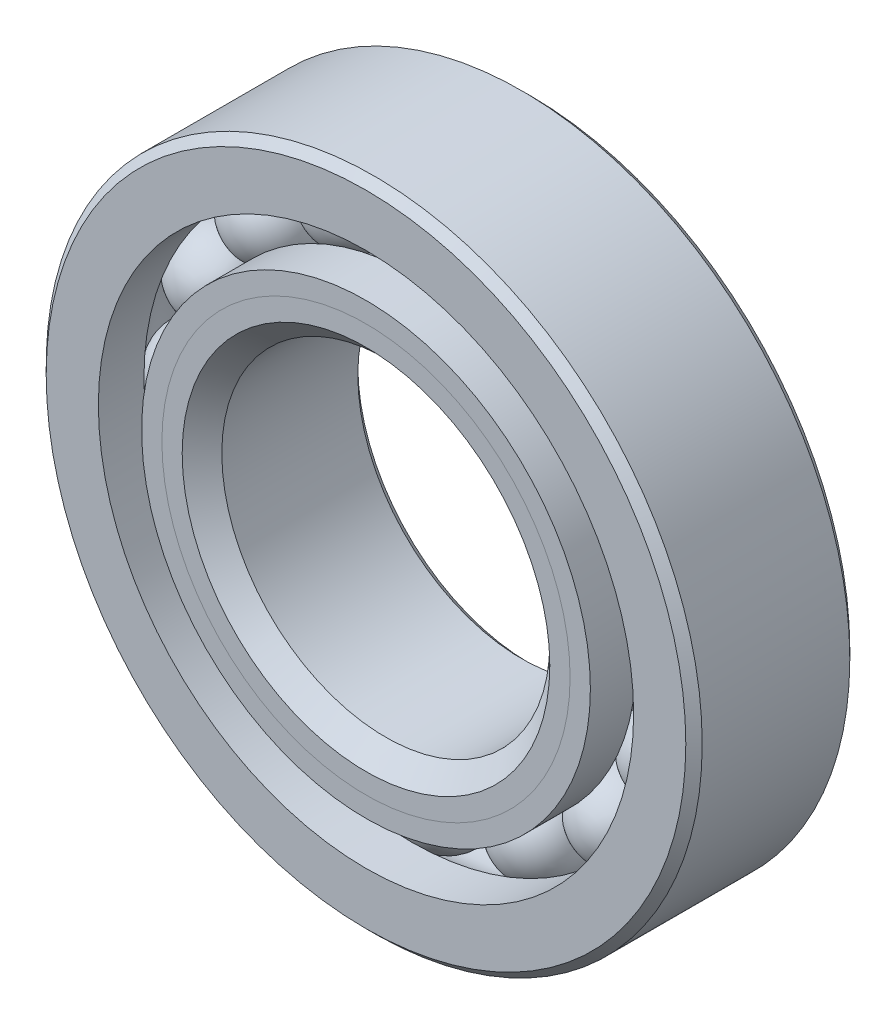
from build123d import *

# Parameters (mm, degrees)
CIRPATTERN1_COUNT = 16


with BuildPart() as part:
    # Sketch1 → Revolve1 (revolve)
    with BuildSketch(Plane(origin=(0, 0, 0), x_dir=(0, 0, -1), z_dir=(1, 0, 0))):
        with BuildLine():
            Line((5.715, 25.4), (-5.715, 25.4))
            Line((-5.715, 25.4), (-6.35, 24.765))
            Line((-6.35, 24.765), (-6.35, 20.724725275))
            Line((-6.35, 20.724725275), (-2.822222222, 20.724725275))
            ThreePointArc((-2.822222222, 20.724725275), (0, 22.331713427), (2.822222222, 20.724725275))
            Line((2.822222222, 20.724725275), (6.35, 20.724725275))
            Line((6.35, 20.724725275), (6.35, 24.765))
            Line((6.35, 24.765), (5.715, 25.4))
        make_face()
    revolve(axis=Axis((0, 0, 6.35), (0, 0, -1)))


with BuildPart() as body_2:
    # Sketch2 → Revolve2 (revolve)
    with BuildSketch(Plane(origin=(0, 0, 0), x_dir=(0, 0, -1), z_dir=(1, 0, 0))):
        with BuildLine():
            Line((-6.35, 17.375274725), (-2.822222222, 17.375274725))
            ThreePointArc((-2.822222222, 17.375274725), (-1.623834135, 16.198192552), (0, 15.768286573))
            Line((0, 15.768286573), (0, 14.234143286))
            Line((0, 14.234143286), (-4.779434281, 14.234143286))
            Line((-4.779434281, 14.234143286), (-6.35, 15.804709006))
            Line((-6.35, 15.804709006), (-6.35, 17.375274725))
        make_face()
    revolve(axis=Axis((0, 0, 6.35), (0, 0, -1)))


with BuildPart() as body_3:
    # Sketch3 → Revolve3 (revolve)
    with BuildSketch(Plane(origin=(0, 0, 0), x_dir=(0, 0, -1), z_dir=(1, 0, 0))):
        with BuildLine():
            Line((-6.35, 15.804709006), (-4.779434281, 14.234143286))
            Line((-4.779434281, 14.234143286), (0, 14.234143286))
            Line((0, 14.234143286), (0, 15.768286573))
            ThreePointArc((0, 15.768286573), (1.623834135, 16.198192552), (2.822222222, 17.375274725))
            Line((2.822222222, 17.375274725), (6.35, 17.375274725))
            Line((6.35, 17.375274725), (6.35, 13.335))
            Line((6.35, 13.335), (5.715, 12.7))
            Line((5.715, 12.7), (-4.815856714, 12.7))
            Line((-4.815856714, 12.7), (-6.35, 14.234143286))
            Line((-6.35, 14.234143286), (-6.35, 15.804709006))
        make_face()
    revolve(axis=Axis((0, 0, 6.35), (0, 0, -1)))


with BuildPart() as body_4:
    # Sketch4 → Revolve4 (revolve)
    with BuildSketch(Plane(origin=(0, 0, 0), x_dir=(0, 0, -1), z_dir=(1, 0, 0))):
        with BuildLine():
            Line((-3.281713427, 19.05), (3.281713427, 19.05))
            ThreePointArc((3.281713427, 19.05), (0, 22.331713427), (-3.281713427, 19.05))
        make_face()
    revolve(axis=Axis((0, 19.05, 3.281713427), (0, 0, -1)))


with BuildPart() as cirpattern1_1:
    # CirPattern1: pattern copy
    add(body_4.part.rotate(Axis((0, 0, -6.35), (0, 0, 1)), 1 * 360 / CIRPATTERN1_COUNT))


with BuildPart() as cirpattern1_2:
    # CirPattern1: pattern copy
    add(body_4.part.rotate(Axis((0, 0, -6.35), (0, 0, 1)), 2 * 360 / CIRPATTERN1_COUNT))


with BuildPart() as cirpattern1_3:
    # CirPattern1: pattern copy
    add(body_4.part.rotate(Axis((0, 0, -6.35), (0, 0, 1)), 3 * 360 / CIRPATTERN1_COUNT))


with BuildPart() as cirpattern1_4:
    # CirPattern1: pattern copy
    add(body_4.part.rotate(Axis((0, 0, -6.35), (0, 0, 1)), 4 * 360 / CIRPATTERN1_COUNT))


with BuildPart() as cirpattern1_5:
    # CirPattern1: pattern copy
    add(body_4.part.rotate(Axis((0, 0, -6.35), (0, 0, 1)), 5 * 360 / CIRPATTERN1_COUNT))


with BuildPart() as cirpattern1_6:
    # CirPattern1: pattern copy
    add(body_4.part.rotate(Axis((0, 0, -6.35), (0, 0, 1)), 6 * 360 / CIRPATTERN1_COUNT))


with BuildPart() as cirpattern1_7:
    # CirPattern1: pattern copy
    add(body_4.part.rotate(Axis((0, 0, -6.35), (0, 0, 1)), 7 * 360 / CIRPATTERN1_COUNT))


with BuildPart() as cirpattern1_8:
    # CirPattern1: pattern copy
    add(body_4.part.rotate(Axis((0, 0, -6.35), (0, 0, 1)), 8 * 360 / CIRPATTERN1_COUNT))


with BuildPart() as cirpattern1_9:
    # CirPattern1: pattern copy
    add(body_4.part.rotate(Axis((0, 0, -6.35), (0, 0, 1)), 9 * 360 / CIRPATTERN1_COUNT))


with BuildPart() as cirpattern1_10:
    # CirPattern1: pattern copy
    add(body_4.part.rotate(Axis((0, 0, -6.35), (0, 0, 1)), 10 * 360 / CIRPATTERN1_COUNT))


with BuildPart() as cirpattern1_11:
    # CirPattern1: pattern copy
    add(body_4.part.rotate(Axis((0, 0, -6.35), (0, 0, 1)), 11 * 360 / CIRPATTERN1_COUNT))


with BuildPart() as cirpattern1_12:
    # CirPattern1: pattern copy
    add(body_4.part.rotate(Axis((0, 0, -6.35), (0, 0, 1)), 12 * 360 / CIRPATTERN1_COUNT))


with BuildPart() as cirpattern1_13:
    # CirPattern1: pattern copy
    add(body_4.part.rotate(Axis((0, 0, -6.35), (0, 0, 1)), 13 * 360 / CIRPATTERN1_COUNT))


with BuildPart() as cirpattern1_14:
    # CirPattern1: pattern copy
    add(body_4.part.rotate(Axis((0, 0, -6.35), (0, 0, 1)), 14 * 360 / CIRPATTERN1_COUNT))


with BuildPart() as cirpattern1_15:
    # CirPattern1: pattern copy
    add(body_4.part.rotate(Axis((0, 0, -6.35), (0, 0, 1)), 15 * 360 / CIRPATTERN1_COUNT))


solid = Compound([part.part, body_2.part, body_3.part, body_4.part, cirpattern1_1.part, cirpattern1_2.part, cirpattern1_3.part, cirpattern1_4.part, cirpattern1_5.part, cirpattern1_6.part, cirpattern1_7.part, cirpattern1_8.part, cirpattern1_9.part, cirpattern1_10.part, cirpattern1_11.part, cirpattern1_12.part, cirpattern1_13.part, cirpattern1_14.part, cirpattern1_15.part])
